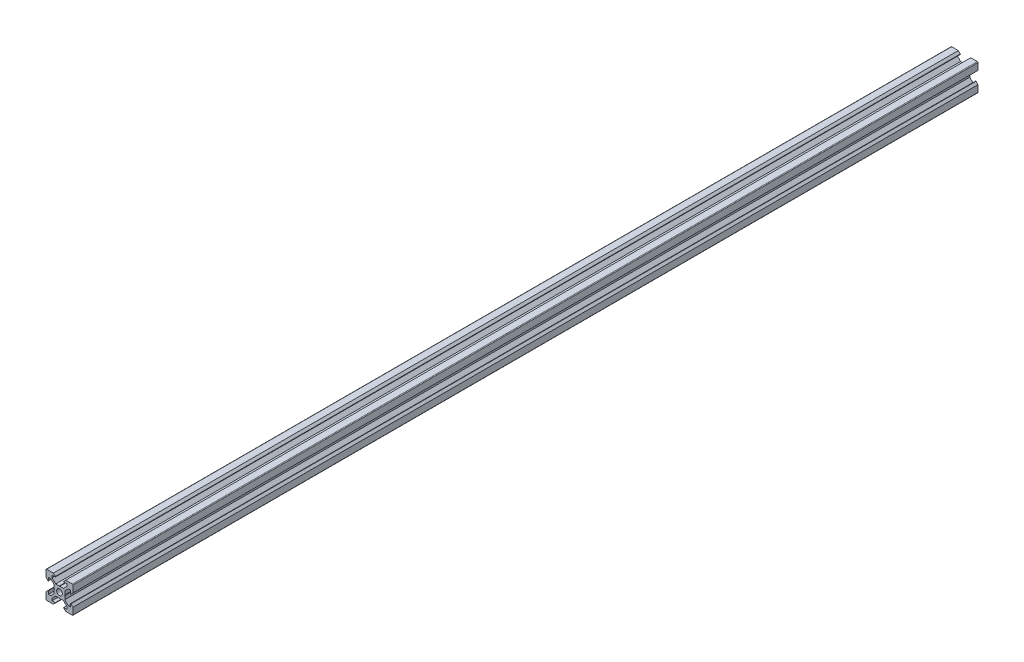
from build123d import *

# Parameters (mm, degrees)
SKETCH1_R           = 2.1
BOSS_EXTRUDE1_DEPTH = 670


with BuildPart() as part:
    # Sketch1 → Boss-Extrude1 (new body)
    with BuildSketch(Plane.XY):
        with BuildLine():
            Line((4.58, -10), (9.5, -10))
            ThreePointArc((9.5, -10), (9.853553391, -9.853553391), (10, -9.5))
            Line((10, -9.5), (10, -4.58))
            Line((10, -4.58), (8.545, -3.125))
            Line((8.545, -3.125), (8.2, -3.125))
            Line((8.2, -3.125), (8.2, -5.5))
            Line((8.2, -5.5), (6.560660172, -5.5))
            Line((6.560660172, -5.5), (3.9, -2.839339828))
            Line((3.9, -2.839339828), (3.9, -0.21))
            Line((3.9, -0.21), (3.69, 0))
            Line((3.69, 0), (3.9, 0.21))
            Line((3.9, 0.21), (3.9, 2.839339828))
            Line((3.9, 2.839339828), (6.560660172, 5.5))
            Line((6.560660172, 5.5), (8.2, 5.5))
            Line((8.2, 5.5), (8.2, 3.125))
            Line((8.2, 3.125), (8.545, 3.125))
            Line((8.545, 3.125), (10, 4.58))
            Line((10, 4.58), (10, 9.5))
            ThreePointArc((10, 9.5), (9.853553391, 9.853553391), (9.5, 10))
            Line((9.5, 10), (4.58, 10))
            Line((4.58, 10), (3.125, 8.545))
            Line((3.125, 8.545), (3.125, 8.2))
            Line((3.125, 8.2), (5.5, 8.2))
            Line((5.5, 8.2), (5.5, 6.560660172))
            Line((5.5, 6.560660172), (2.839339828, 3.9))
            Line((2.839339828, 3.9), (0.21, 3.9))
            Line((0.21, 3.9), (0, 3.69))
            Line((0, 3.69), (-0.21, 3.9))
            Line((-0.21, 3.9), (-2.839339828, 3.9))
            Line((-2.839339828, 3.9), (-5.5, 6.560660172))
            Line((-5.5, 6.560660172), (-5.5, 8.2))
            Line((-5.5, 8.2), (-3.125, 8.2))
            Line((-3.125, 8.2), (-3.125, 8.545))
            Line((-3.125, 8.545), (-4.58, 10))
            Line((-4.58, 10), (-9.5, 10))
            ThreePointArc((-9.5, 10), (-9.853553391, 9.853553391), (-10, 9.5))
            Line((-10, 9.5), (-10, 4.58))
            Line((-10, 4.58), (-8.545, 3.125))
            Line((-8.545, 3.125), (-8.2, 3.125))
            Line((-8.2, 3.125), (-8.2, 5.5))
            Line((-8.2, 5.5), (-6.560660172, 5.5))
            Line((-6.560660172, 5.5), (-3.9, 2.839339828))
            Line((-3.9, 2.839339828), (-3.9, 0.21))
            Line((-3.9, 0.21), (-3.69, 0))
            Line((-3.69, 0), (-3.9, -0.21))
            Line((-3.9, -0.21), (-3.9, -2.839339828))
            Line((-3.9, -2.839339828), (-6.560660172, -5.5))
            Line((-6.560660172, -5.5), (-8.2, -5.5))
            Line((-8.2, -5.5), (-8.2, -3.125))
            Line((-8.2, -3.125), (-8.545, -3.125))
            Line((-8.545, -3.125), (-10, -4.58))
            Line((-10, -4.58), (-10, -9.5))
            ThreePointArc((-10, -9.5), (-9.853553391, -9.853553391), (-9.5, -10))
            Line((-9.5, -10), (-4.58, -10))
            Line((-4.58, -10), (-3.125, -8.545))
            Line((-3.125, -8.545), (-3.125, -8.2))
            Line((-3.125, -8.2), (-5.5, -8.2))
            Line((-5.5, -8.2), (-5.5, -6.560660172))
            Line((-5.5, -6.560660172), (-2.839339828, -3.9))
            Line((-2.839339828, -3.9), (-0.21, -3.9))
            Line((-0.21, -3.9), (0, -3.69))
            Line((0, -3.69), (0.21, -3.9))
            Line((0.21, -3.9), (2.839339828, -3.9))
            Line((2.839339828, -3.9), (5.5, -6.560660172))
            Line((5.5, -6.560660172), (5.5, -8.2))
            Line((5.5, -8.2), (3.125, -8.2))
            Line((3.125, -8.2), (3.125, -8.545))
            Line((3.125, -8.545), (4.58, -10))
        make_face()
        Circle(SKETCH1_R, mode=Mode.SUBTRACT)
    extrude(amount=BOSS_EXTRUDE1_DEPTH)


solid = part.part
